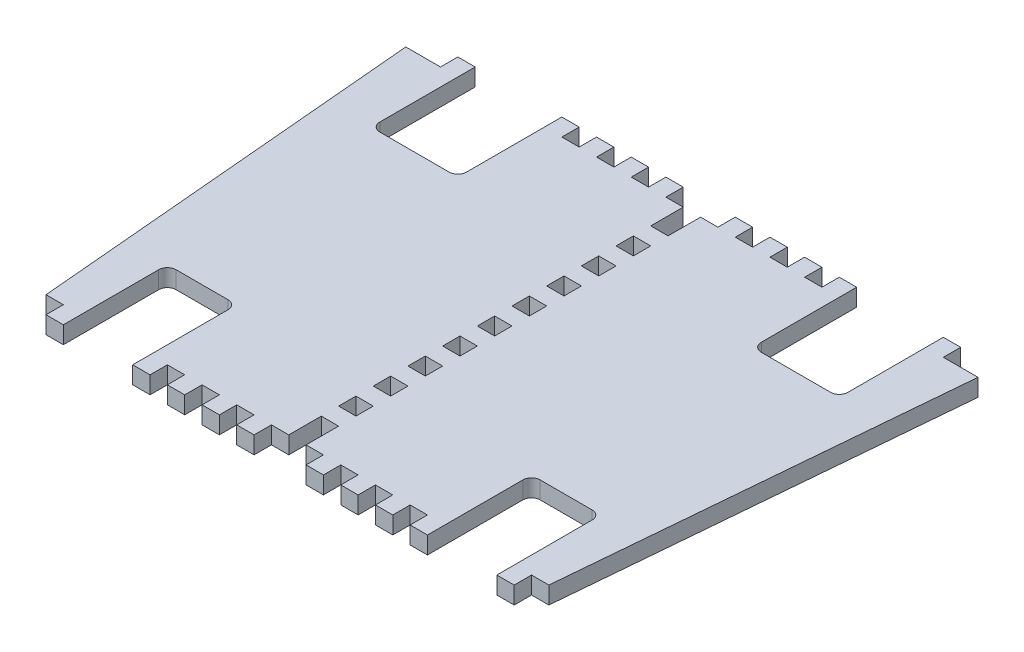
from build123d import *

# Parameters (mm, degrees)
SKETCH1_W           = 4
SKETCH1_H           = 4
BOSS_EXTRUDE1_DEPTH = 4
SKETCH2_W           = 4
SKETCH2_H           = 4
BOSS_EXTRUDE2_DEPTH = 4
CUT_EXTRUDE2_DEPTH  = 4


with BuildPart() as part:
    # Sketch1 → Boss-Extrude1 (new body)
    with BuildSketch(Plane(origin=(0, 0, 0), x_dir=(1, 0, 0), z_dir=(0, 1, 0))):
        Polygon((-66, 34.024336283), (-2, 34.024336283), (-2, 26.524336283), (2, 26.524336283), (2, 34.024336283), (66, 34.024336283), (58, -56.975663717), (2, -56.975663717), (2, -49.475663717), (-2, -49.475663717), (-2, -56.975663717), (-58, -56.975663717), align=None)
        with Locations((0, -3.475663717)):
            Rectangle(SKETCH1_W, SKETCH1_H, mode=Mode.SUBTRACT)
        with Locations((0, -11.475663717)):
            Rectangle(SKETCH1_W, SKETCH1_H, mode=Mode.SUBTRACT)
        with Locations((0, 4.524336283)):
            Rectangle(SKETCH1_W, SKETCH1_H, mode=Mode.SUBTRACT)
        with Locations((0, 12.524336283)):
            Rectangle(SKETCH1_W, SKETCH1_H, mode=Mode.SUBTRACT)
        with Locations((0, 20.524336283)):
            Rectangle(SKETCH1_W, SKETCH1_H, mode=Mode.SUBTRACT)
        with Locations((0, -19.475663717)):
            Rectangle(SKETCH1_W, SKETCH1_H, mode=Mode.SUBTRACT)
        with Locations((0, -27.475663717)):
            Rectangle(SKETCH1_W, SKETCH1_H, mode=Mode.SUBTRACT)
        with Locations((0, -35.475663717)):
            Rectangle(SKETCH1_W, SKETCH1_H, mode=Mode.SUBTRACT)
        with Locations((0, -43.475663717)):
            Rectangle(SKETCH1_W, SKETCH1_H, mode=Mode.SUBTRACT)
    extrude(amount=BOSS_EXTRUDE1_DEPTH)

    # Sketch2 → Boss-Extrude2 (add)
    with BuildSketch(Plane(origin=(0, 4, 0), x_dir=(1, 0, 0), z_dir=(0, 1, 0))):
        with Locations((-8, 36.024336283)):
            Rectangle(SKETCH2_W, SKETCH2_H)
        with Locations((-16, 36.024336283)):
            Rectangle(SKETCH2_W, SKETCH2_H)
        with Locations((-24, 36.024336283)):
            Rectangle(SKETCH2_W, SKETCH2_H)
        with Locations((-32, 36.024336283)):
            Rectangle(SKETCH2_W, SKETCH2_H)
        with Locations((56, 36.024336283)):
            Rectangle(SKETCH2_W, SKETCH2_H)
        with Locations((32, 36.024336283)):
            Rectangle(SKETCH2_W, SKETCH2_H)
        with Locations((-56, 36.024336283)):
            Rectangle(SKETCH2_W, SKETCH2_H)
        with Locations((24, 36.024336283)):
            Rectangle(SKETCH2_W, SKETCH2_H)
        with Locations((16, 36.024336283)):
            Rectangle(SKETCH2_W, SKETCH2_H)
        with Locations((8, 36.024336283)):
            Rectangle(SKETCH2_W, SKETCH2_H)
        with Locations((8, -58.975663717)):
            Rectangle(SKETCH2_W, SKETCH2_H)
        with Locations((16, -58.975663717)):
            Rectangle(SKETCH2_W, SKETCH2_H)
        with Locations((24, -58.975663717)):
            Rectangle(SKETCH2_W, SKETCH2_H)
        with Locations((32, -58.975663717)):
            Rectangle(SKETCH2_W, SKETCH2_H)
        with Locations((-52, -58.975663717)):
            Rectangle(SKETCH2_W, SKETCH2_H)
        with Locations((52, -58.975663717)):
            Rectangle(SKETCH2_W, SKETCH2_H)
        with Locations((-32, -58.975663717)):
            Rectangle(SKETCH2_W, SKETCH2_H)
        with Locations((-24, -58.975663717)):
            Rectangle(SKETCH2_W, SKETCH2_H)
        with Locations((-16, -58.975663717)):
            Rectangle(SKETCH2_W, SKETCH2_H)
        with Locations((-8, -58.975663717)):
            Rectangle(SKETCH2_W, SKETCH2_H)
    extrude(amount=-BOSS_EXTRUDE2_DEPTH)

    # Sketch3 → Cut-Extrude2 (cut)
    with BuildSketch(Plane(origin=(0, 4, 0), x_dir=(1, 0, 0), z_dir=(0, 1, 0))):
        with BuildLine():
            Line((-54, 34.024336283), (-54, 16.024336283))
            ThreePointArc((-54, 16.024336283), (-53.414213562, 14.610122721), (-52, 14.024336283))
            Line((-52, 14.024336283), (-36, 14.024336283))
            ThreePointArc((-36, 14.024336283), (-34.585786438, 14.610122721), (-34, 16.024336283))
            Line((-34, 16.024336283), (-34, 34.024336283))
            Line((-34, 34.024336283), (-54, 34.024336283))
        make_face()
        with BuildLine():
            Line((54, 34.024336283), (34, 34.024336283))
            Line((34, 34.024336283), (34, 16.024336283))
            ThreePointArc((34, 16.024336283), (34.585786438, 14.610122721), (36, 14.024336283))
            Line((36, 14.024336283), (52, 14.024336283))
            ThreePointArc((52, 14.024336283), (53.414213562, 14.610122721), (54, 16.024336283))
            Line((54, 16.024336283), (54, 34.024336283))
        make_face()
        with BuildLine():
            Line((-34, -56.975663717), (-50, -56.975663717))
            Line((-50, -56.975663717), (-50, -38.975663717))
            ThreePointArc((-50, -38.975663717), (-49.414213562, -37.561450154), (-48, -36.975663717))
            Line((-48, -36.975663717), (-36, -36.975663717))
            ThreePointArc((-36, -36.975663717), (-34.585786438, -37.561450154), (-34, -38.975663717))
            Line((-34, -38.975663717), (-34, -56.975663717))
        make_face()
        with BuildLine():
            Line((34, -56.975663717), (50, -56.975663717))
            Line((50, -56.975663717), (50, -38.975663717))
            ThreePointArc((50, -38.975663717), (49.414213562, -37.561450154), (48, -36.975663717))
            Line((48, -36.975663717), (36, -36.975663717))
            ThreePointArc((36, -36.975663717), (34.585786438, -37.561450154), (34, -38.975663717))
            Line((34, -38.975663717), (34, -56.975663717))
        make_face()
    extrude(amount=-CUT_EXTRUDE2_DEPTH, mode=Mode.SUBTRACT)


solid = part.part
